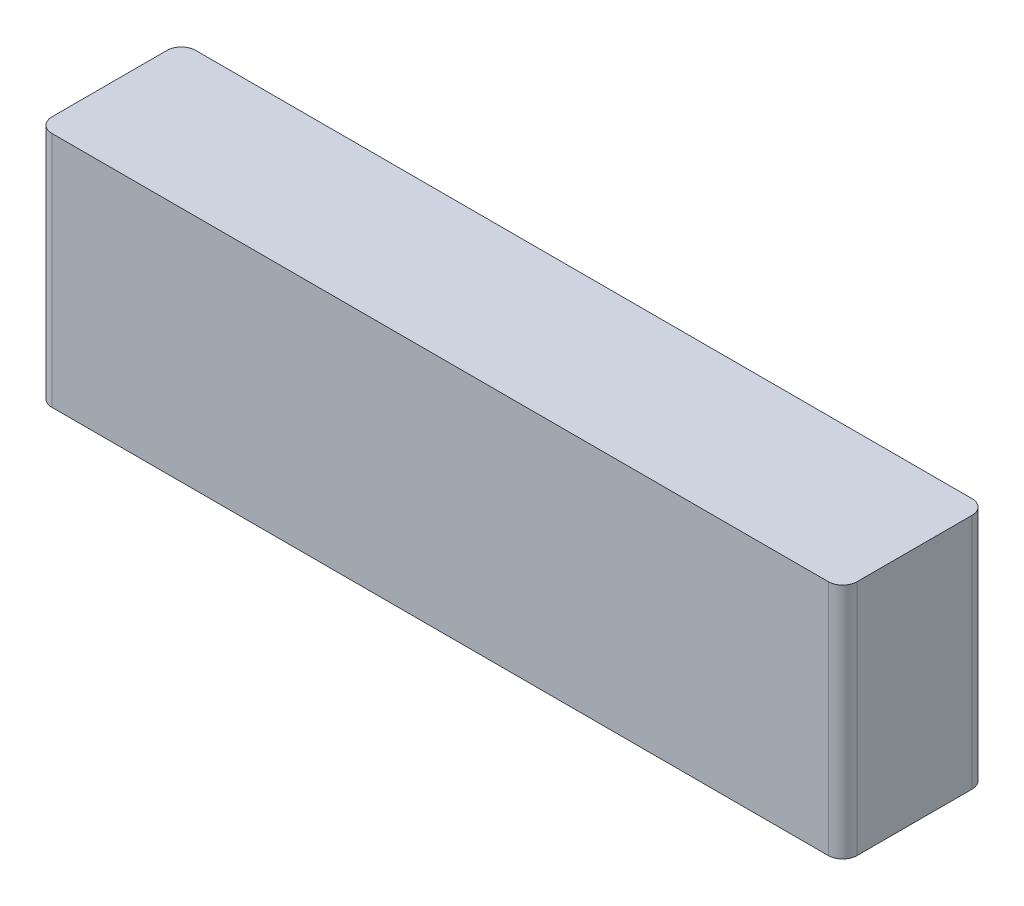
from build123d import *

# Parameters (mm, degrees)
SKETCH1_W           = 112
SKETCH1_H           = 20
BOSS_EXTRUDE1_DEPTH = 33
FILLET1_R           = 2


with BuildPart() as part:
    # Sketch1 → Boss-Extrude1 (new body)
    with BuildSketch(Plane(origin=(0, 0, 0), x_dir=(1, 0, 0), z_dir=(0, 1, 0))):
        Rectangle(SKETCH1_W, SKETCH1_H)
    extrude(amount=BOSS_EXTRUDE1_DEPTH)

    # Fillet1
    fillet1_edges = [part.edges().sort_by_distance(p)[0] for p in [
        (56, 16.5, 10),
        (-56, 16.5, 10),
        (-56, 16.5, -10),
        (56, 16.5, -10),
    ]]
    fillet(fillet1_edges, radius=FILLET1_R)


solid = part.part
